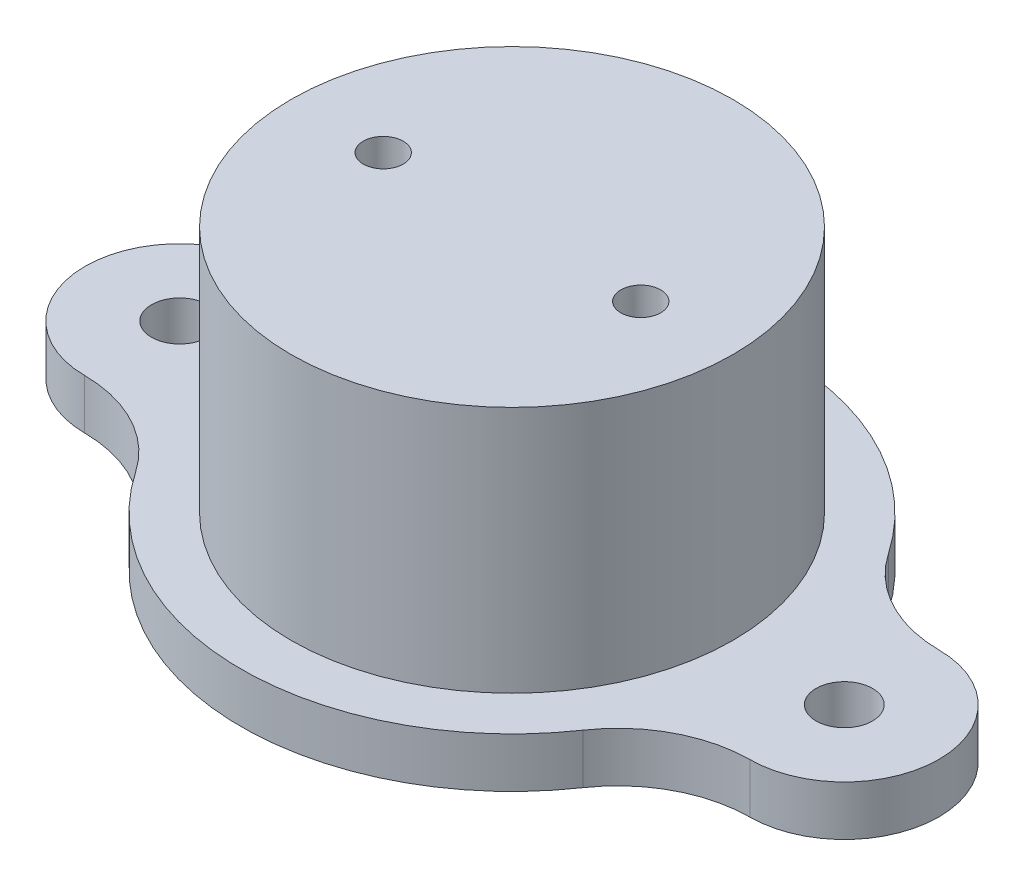
from build123d import *

# Parameters (mm, degrees)
SKETCH3_R           = 1.7
BOSS_EXTRUDE4_DEPTH = 3
CUT_EXTRUDE3_REACH  = 5
SKETCH4_R           = 1.2


with BuildPart() as part:
    # Sketch1 → Revolve1 (revolve)
    with BuildSketch(Plane.XY):
        Polygon((11.7, 0), (0, 0), (0, 3), (13.3, 3), (13.3, -16), (11.7, -16), align=None)
        Polygon((16.3, -11.9), (13.3, -11.9), (13.3, -16), (16.3, -14.9), align=None)
    revolve(axis=Axis((0, -272.323852837, 0), (0, 1, 0)))

    # Sketch3 → Boss-Extrude4 (add)
    with BuildSketch(Plane(origin=(0, -11.9, 0), x_dir=(1, 0, 0), z_dir=(0, 1, 0))):
        with BuildLine():
            ThreePointArc((-20.029124088, 5.699925595), (-25.7, 0), (-20.029124088, -5.699925595))
            ThreePointArc((-20.029124088, -5.699925595), (-16.315754318, -6.635428811), (-13.462592593, -9.189591976))
            ThreePointArc((-13.462592593, -9.189591976), (-16.3, 0), (-13.462592593, 9.189591976))
            ThreePointArc((-13.462592593, 9.189591976), (-16.315754318, 6.635428811), (-20.029124088, 5.699925595))
        make_face()
        with Locations((-20, 0)):
            Circle(SKETCH3_R, mode=Mode.SUBTRACT)
        with BuildLine():
            ThreePointArc((13.462592593, -9.189591976), (16.3, 0), (13.462592593, 9.189591976))
            ThreePointArc((13.462592593, 9.189591976), (16.315754318, 6.635428811), (20.029124088, 5.699925595))
            ThreePointArc((20.029124088, 5.699925595), (25.7, 0), (20.029124088, -5.699925595))
            ThreePointArc((20.029124088, -5.699925595), (16.315754318, -6.635428811), (13.462592593, -9.189591976))
        make_face()
        with Locations((20, 0)):
            Circle(SKETCH3_R, mode=Mode.SUBTRACT)
    extrude(amount=-BOSS_EXTRUDE4_DEPTH)

    # Sketch4 → Cut-Extrude3 (cut, up to next)
    with BuildSketch(Plane(origin=(0, 0, 0), x_dir=(1, 0, 0), z_dir=(0, 1, 0)), mode=Mode.PRIVATE) as cut_extrude3_sk1:
        with Locations((7.75, 0)):
            Circle(SKETCH4_R)
    cut_extrude3_tool1 = extrude(cut_extrude3_sk1.sketch, amount=CUT_EXTRUDE3_REACH, mode=Mode.PRIVATE) & part.part
    add(cut_extrude3_tool1.solids().sort_by_distance((7.75, 0, 0))[0], mode=Mode.SUBTRACT)
    # Sketch4 → Cut-Extrude3 (cut, up to next)
    with BuildSketch(Plane(origin=(0, 0, 0), x_dir=(1, 0, 0), z_dir=(0, 1, 0)), mode=Mode.PRIVATE) as cut_extrude3_sk2:
        with Locations((-7.75, 0)):
            Circle(SKETCH4_R)
    cut_extrude3_tool2 = extrude(cut_extrude3_sk2.sketch, amount=CUT_EXTRUDE3_REACH, mode=Mode.PRIVATE) & part.part
    add(cut_extrude3_tool2.solids().sort_by_distance((-7.75, 0, 0))[0], mode=Mode.SUBTRACT)


solid = part.part
